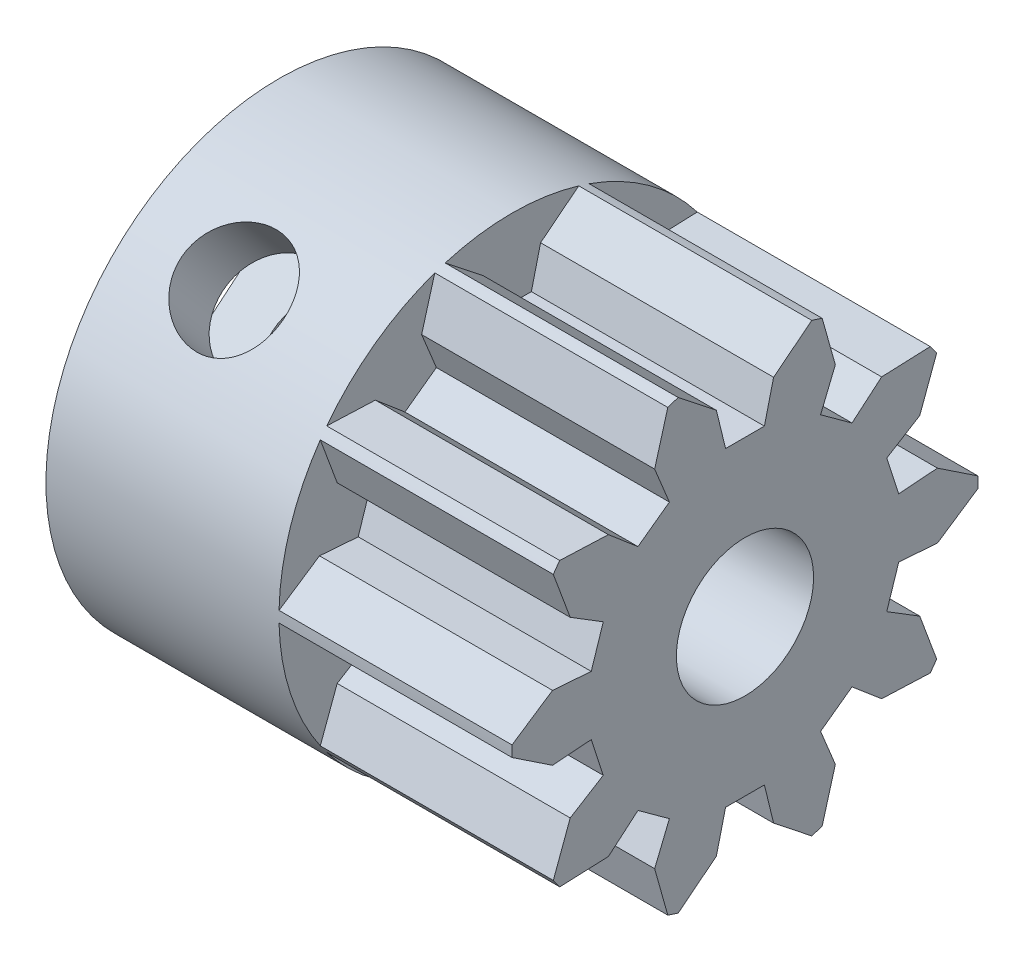
from build123d import *

# Parameters (mm, degrees)
ESQUISSE1_R                  = 9
ESQUISSE1_R_2                = 2.65
BOSS_EXTRU_1_DEPTH           = 18
ENL_V_MAT_EXTRU_2_DEPTH      = 9
R_P_TITION_CIRCULAIRE1_COUNT = 10
ESQUISSE6_W                  = 3
ESQUISSE6_H                  = 6
ENL_V_MAT_EXTRU_3_DEPTH      = 7
ESQUISSE7_R                  = 2
ENL_V_MAT_EXTRU_4_DEPTH      = 9
R_P_TITION_CIRCULAIRE2_COUNT = 2
R_P_TITION_CIRCULAIRE2_ANGLE = 130


with BuildPart() as part:
    # Esquisse1 → Boss.-Extru.1 (new body)
    with BuildSketch(Plane(origin=(0, 0, 0), x_dir=(0, 0, -1), z_dir=(1, 0, 0))):
        Circle(ESQUISSE1_R)
        Circle(ESQUISSE1_R_2, mode=Mode.SUBTRACT)
    extrude(amount=BOSS_EXTRU_1_DEPTH)

    # Esquisse5 → Enlèv. mat.-Extru.2 (cut)
    with BuildSketch(Plane(origin=(18, 0, 0), x_dir=(0, 0, -1), z_dir=(1, 0, 0))):
        with BuildLine():
            Line((-0.75, 6), (0.75, 6))
            Line((0.75, 6), (1.105, 7.457386359))
            Line((1.105, 7.457386359), (2.579613997, 8.622388974))
            ThreePointArc((2.579613997, 8.622388974), (0, 9), (-2.579613997, 8.622388974))
            Line((-2.579613997, 8.622388974), (-1.105, 7.457386359))
            Line((-1.105, 7.457386359), (-0.75, 6))
        make_face()
    enl_v_mat_extru_2 = extrude(amount=-ENL_V_MAT_EXTRU_2_DEPTH, mode=Mode.SUBTRACT)

    # Répétition circulaire1: Enlèv. mat.-Extru.2 ×10 about axis
    r_p_tition_circulaire1_axis = Axis((0, 0, 0), (1, 0, 0))
    for i in range(1, R_P_TITION_CIRCULAIRE1_COUNT):
        add(enl_v_mat_extru_2.rotate(r_p_tition_circulaire1_axis, i * 360 / R_P_TITION_CIRCULAIRE1_COUNT), mode=Mode.SUBTRACT)

    # Esquisse6 → Enlèv. mat.-Extru.3 (cut)
    with BuildSketch(Plane.ZY):
        with Locations((-5, 0)):
            Rectangle(ESQUISSE6_W, ESQUISSE6_H)
    enl_v_mat_extru_3 = extrude(amount=-ENL_V_MAT_EXTRU_3_DEPTH, mode=Mode.SUBTRACT)

    # Esquisse7 → Enlèv. mat.-Extru.4 (cut)
    with BuildSketch(Plane(origin=(0, 0, -9), x_dir=(-1, 0, 0), z_dir=(0, 0, -1))):
        with Locations((-4, 0)):
            Circle(ESQUISSE7_R)
    enl_v_mat_extru_4 = extrude(amount=-ENL_V_MAT_EXTRU_4_DEPTH, mode=Mode.SUBTRACT)

    # Répétition circulaire2: Enlèv. mat.-Extru.3, Enlèv. mat.-Extru.4 ×2 about axis
    r_p_tition_circulaire2_axis = Axis((0, 0, 0), (1, 0, 0))
    for i in range(1, R_P_TITION_CIRCULAIRE2_COUNT):
        add(enl_v_mat_extru_3.rotate(r_p_tition_circulaire2_axis, i * R_P_TITION_CIRCULAIRE2_ANGLE / (R_P_TITION_CIRCULAIRE2_COUNT - 1)), mode=Mode.SUBTRACT)
        add(enl_v_mat_extru_4.rotate(r_p_tition_circulaire2_axis, i * R_P_TITION_CIRCULAIRE2_ANGLE / (R_P_TITION_CIRCULAIRE2_COUNT - 1)), mode=Mode.SUBTRACT)


solid = part.part
